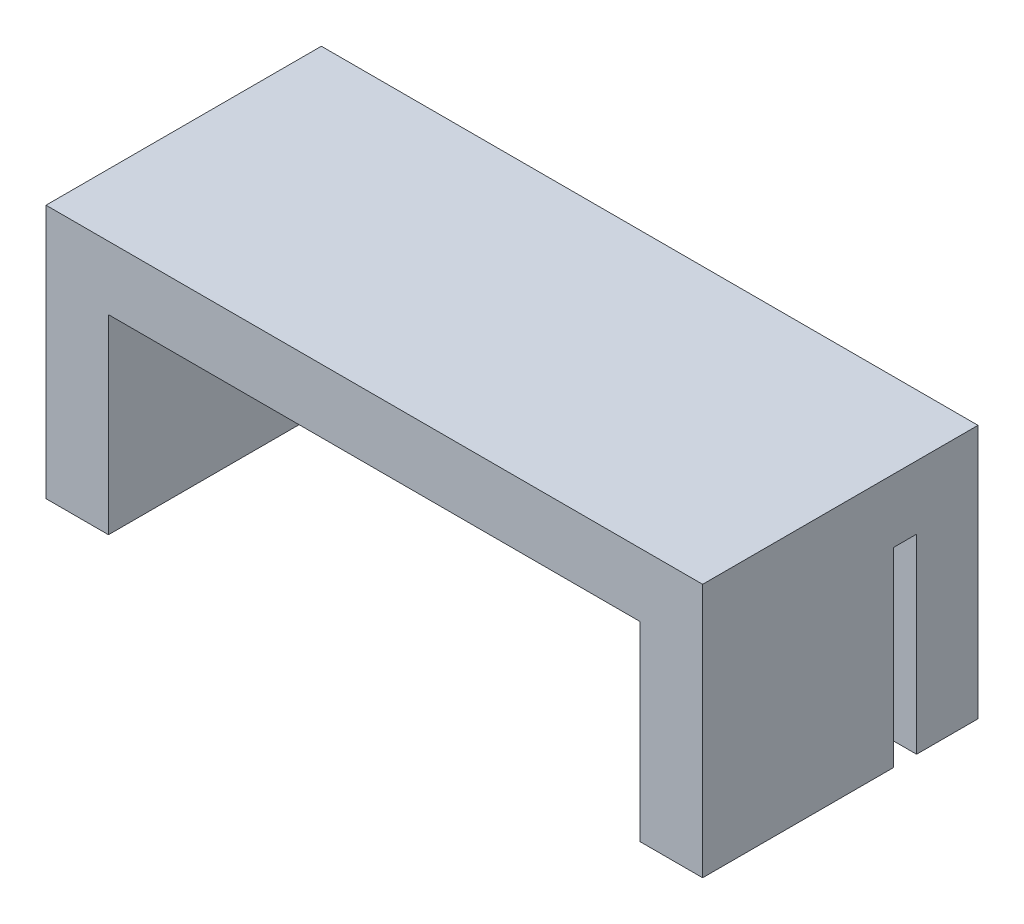
from build123d import *

# Parameters (mm, degrees)
CROQUIS2_W              = 31
CROQUIS2_H              = 12
SALIENTE_EXTRUIR1_DEPTH = 13
CROQUIS3_W              = 25.1
CROQUIS3_H              = 10.1
CORTAR_EXTRUIR1_DEPTH   = 9
CROQUIS6_W              = 1.1
CROQUIS6_H              = 9
CORTAR_EXTRUIR3_DEPTH   = 32
CROQUIS7_R              = 1.5
CORTAR_EXTRUIR4_DEPTH   = 14


with BuildPart() as part:
    # Croquis2 → Saliente-Extruir1 (new body)
    with BuildSketch(Plane.XY):
        Rectangle(CROQUIS2_W, CROQUIS2_H)
    extrude(amount=SALIENTE_EXTRUIR1_DEPTH)

    # Croquis3 → Cortar-Extruir1 (cut)
    with BuildSketch(Plane.XZ.offset(6)):
        with Locations((0, 7.95)):
            Rectangle(CROQUIS3_W, CROQUIS3_H)
    extrude(amount=-CORTAR_EXTRUIR1_DEPTH, mode=Mode.SUBTRACT)

    # Croquis6 → Cortar-Extruir3 (cut, through all)
    with BuildSketch(Plane.ZY.offset(15.5)):
        with Locations((3.45, -1.5)):
            Rectangle(CROQUIS6_W, CROQUIS6_H)
    extrude(amount=-CORTAR_EXTRUIR3_DEPTH, mode=Mode.SUBTRACT)

    # Croquis7 → Cortar-Extruir4 (cut, through all)
    with BuildSketch(Plane(origin=(0, 0, 0), x_dir=(-1, 0, 0), z_dir=(0, 0, -1))):
        with Locations((-8.4125, -2.05)):
            Circle(CROQUIS7_R)
        with Locations((8.4125, -2.05)):
            Circle(CROQUIS7_R)
    extrude(amount=-CORTAR_EXTRUIR4_DEPTH, mode=Mode.SUBTRACT)


solid = part.part
